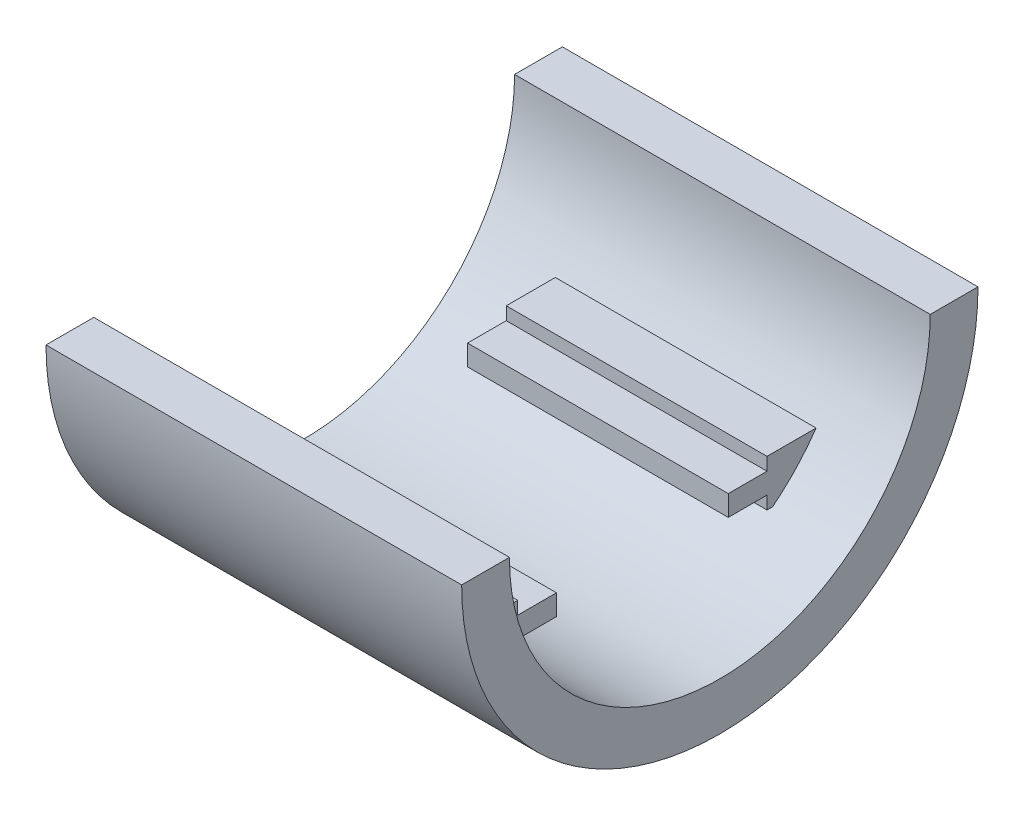
from build123d import *

# Parameters (mm, degrees)
SKETCH1_W                       = 40.894
SKETCH1_H                       = 25.4
REVOLVE1_ANGLE                  = 180
BOSS_EXTRUDE1_REACH             = 27.4
SKETCH3_W                       = 25.654
SKETCH3_H                       = 4.572
BOSS_EXTRUDE1_DIRECTION_2_REACH = 27.4
SKETCH4_W                       = 25.654
SKETCH4_H                       = 24.524924672
CUT_EXTRUDE1_DEPTH              = 4.572
SKETCH5_W                       = 3.81
SKETCH5_H                       = 2.032
BOSS_EXTRUDE2_DEPTH             = 25.654


with BuildPart() as part:
    # Sketch1 → Revolve1 (revolve)
    with BuildSketch(Plane(origin=(0, 0, 0), x_dir=(1, 0, 0), z_dir=(0, 1, 0))):
        with Locations((20.447, -12.7)):
            Rectangle(SKETCH1_W, SKETCH1_H)
    revolve(axis=Axis((0, 0, 0), (1, 0, 0)), revolution_arc=REVOLVE1_ANGLE)

    # Sketch2 → Cut-Revolve1 (revolve, cut)
    with BuildSketch(Plane(origin=(0, 0, 0), x_dir=(1, 0, 0), z_dir=(0, 1, 0))):
        Polygon((0, 0), (41.402, 0), (41.402, -20.701), (40.132, -20.701), (1.27, -20.701), (0, -20.701), align=None)
    revolve(axis=Axis((0, 0, 0), (1, 0, 0)), mode=Mode.SUBTRACT)

    # Sketch3 → Boss-Extrude1 (add, up to next)
    with BuildSketch(Plane.XY, mode=Mode.PRIVATE) as boss_extrude1_sk1:
        with Locations((20.447, -13.97)):
            Rectangle(SKETCH3_W, SKETCH3_H)
    boss_extrude1_tool1 = extrude(boss_extrude1_sk1.sketch, amount=BOSS_EXTRUDE1_REACH, mode=Mode.PRIVATE) - part.part
    add(boss_extrude1_tool1.solids().sort_by_distance((20.447, -13.97, 0))[0])

    # Sketch3 → Boss-Extrude1 direction 2 (add, up to next)
    with BuildSketch(Plane.XY, mode=Mode.PRIVATE) as boss_extrude1_direction_2_sk1:
        with Locations((20.447, -13.97)):
            Rectangle(SKETCH3_W, SKETCH3_H)
    boss_extrude1_direction_2_tool1 = extrude(boss_extrude1_direction_2_sk1.sketch, amount=-BOSS_EXTRUDE1_DIRECTION_2_REACH, mode=Mode.PRIVATE) - part.part
    add(boss_extrude1_direction_2_tool1.solids().sort_by_distance((20.447, -13.97, 0))[0])

    # Sketch4 → Cut-Extrude1 (cut)
    with BuildSketch(Plane(origin=(0, -11.684, 0), x_dir=(1, 0, 0), z_dir=(0, 1, 0))):
        with Locations((20.447, 0)):
            Rectangle(SKETCH4_W, SKETCH4_H)
    extrude(amount=-CUT_EXTRUDE1_DEPTH, mode=Mode.SUBTRACT)

    # Sketch5 → Boss-Extrude2 (add)
    with BuildSketch(Plane.ZY.offset(-7.62)):
        with Locations((-10.357462336, -13.97)):
            Rectangle(SKETCH5_W, SKETCH5_H)
        with Locations((10.357462336, -13.97)):
            Rectangle(SKETCH5_W, SKETCH5_H)
    extrude(amount=-BOSS_EXTRUDE2_DEPTH)


solid = part.part
